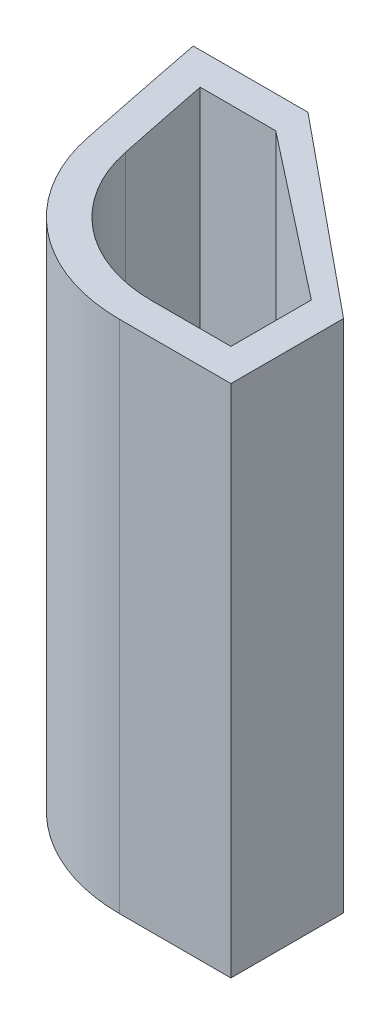
from build123d import *

# Parameters (mm, degrees)
BOSS_EXTRUDE1_DEPTH = 16
CUT_EXTRUDE1_REACH  = 10.836
SKETCH2_R           = 1.6


with BuildPart() as part:
    # Sketch1 → Boss-Extrude1 (new body)
    with BuildSketch(Plane(origin=(0, 0, 0), x_dir=(1, 0, 0), z_dir=(0, 1, 0))):
        with BuildLine():
            Line((-1.728929985, 4.409979173), (-5.295587342, 4.409979173))
            ThreePointArc((-5.295587342, 4.409979173), (-4.887048333, 2.349132427), (-4.465862239, 0.290833199))
            ThreePointArc((-4.465862239, 0.290833199), (-2.551857479, -2.856477369), (0.919071585, -4.090020827))
            Line((0.919071585, -4.090020827), (4.376171699, -4.090020827))
            Line((4.376171699, -4.090020827), (4.376171699, -0.590020827))
            Line((4.376171699, -0.590020827), (-1.728929985, 4.409979173))
        make_face()
        with BuildLine():
            Line((-1.728929985, 3.409979173), (3.376171699, -0.590020827))
            Line((3.376171699, -0.590020827), (3.376171699, -3.090020827))
            Line((3.376171699, -3.090020827), (0.919071585, -3.090020827))
            ThreePointArc((0.919071585, -3.090020827), (-1.920779468, -2.080757998), (-3.486783362, 0.494314286))
            ThreePointArc((-3.486783362, 0.494314286), (-3.786316073, 1.951500554), (-4.079491423, 3.409979173))
            Line((-4.079491423, 3.409979173), (-1.728929985, 3.409979173))
        make_face(mode=Mode.SUBTRACT)
    extrude(amount=BOSS_EXTRUDE1_DEPTH)

    # Cut-Extrude1: up to this face of the body (flat: up to its plane)
    cut_extrude1_end = Plane(part.part.faces().sort_by_distance((0.823620857, 8, -1.409979173))[0])
    # Sketch2 → Cut-Extrude1 (cut, up to the picked face)
    with BuildSketch(Plane(origin=(1.467645419, 0, -1.792024904), x_dir=(-0.773651844, 0, -0.633610941), z_dir=(0.633610941, 0, -0.773651844)), mode=Mode.PRIVATE) as cut_extrude1_sk1:
        with Locations((0.093080992, 8)):
            Circle(SKETCH2_R)
    cut_extrude1_tool1 = split(extrude(cut_extrude1_sk1.sketch, amount=-CUT_EXTRUDE1_REACH, mode=Mode.PRIVATE), bisect_by=cut_extrude1_end, keep=Keep.BOTH, mode=Mode.PRIVATE)
    add(cut_extrude1_tool1.solids().sort_by_distance((1.395633, 8, -1.851002))[0], mode=Mode.SUBTRACT)


solid = part.part
